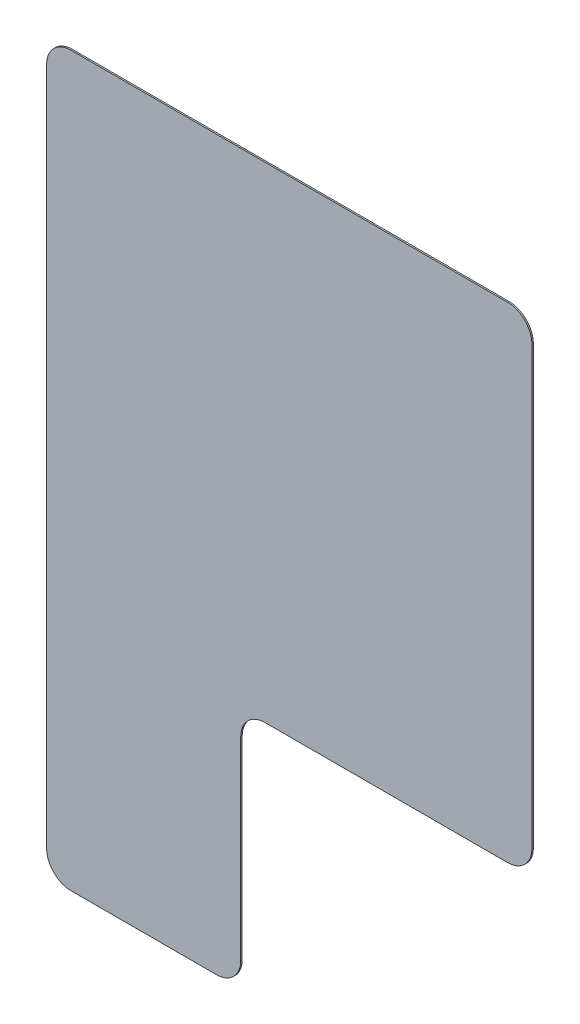
from build123d import *

# Parameters (mm, degrees)
SKETCH1_W           = 2
SKETCH1_H           = 2.5
SKETCH1_W_2         = 5
SKETCH1_H_2         = 5
BOSS_EXTRUDE1_DEPTH = 0.015
FILLET1_R           = 0.25


with BuildPart() as part:
    # Sketch1 → Boss-Extrude1 (new body)
    with BuildSketch(Plane.XY):
        with Locations((-1.5, -3.75)):
            Rectangle(SKETCH1_W, SKETCH1_H)
        Rectangle(SKETCH1_W_2, SKETCH1_H_2)
    extrude(amount=BOSS_EXTRUDE1_DEPTH)

    # Fillet1
    fillet1_edges = [part.edges().sort_by_distance(p)[0] for p in [
        (-0.5, -5, 0.0075),
        (-2.5, -5, 0.0075),
        (-2.5, 2.5, 0.0075),
        (2.5, 2.5, 0.0075),
        (2.5, -2.5, 0.0075),
        (-0.5, -2.5, 0.0075),
    ]]
    fillet(fillet1_edges, radius=FILLET1_R)


solid = part.part
